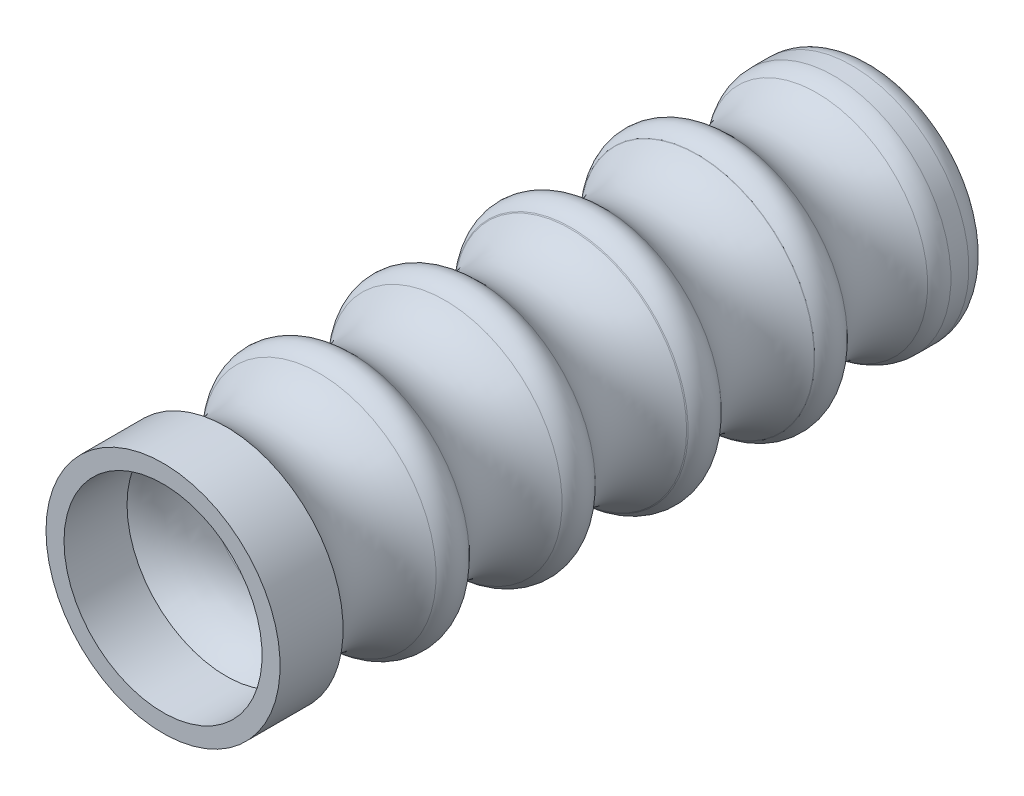
from build123d import *


with BuildPart() as part:
    # Esboço2 → Revolução1 (revolve)
    with BuildSketch(Plane(origin=(0, 0, 0), x_dir=(1, 0, 0), z_dir=(0, 1, 0))):
        with BuildLine():
            Line((8.556122621, -12.161308069), (6.556122621, -12.161308069))
            Line((6.556122621, -12.161308069), (6.556122621, -5.161308069))
            add(Edge.make_bspline(
                [(6.556122621, -5.161308069), (3.760010481, -2.137867698), (4.623751666, 1.838691931)],
                knots=[0, 0, 0, 1, 1, 1], degree=2))
            Line((4.623751666, 1.838691931), (4.623751666, 66.838691931))
            Line((4.623751666, 66.838691931), (6.056124965, 66.838691931))
            ThreePointArc((6.056124965, 66.838691931), (7.823891918, 66.106458884), (8.556124965, 64.338691931))
            Line((8.556124965, 64.338691931), (8.556124965, 62.345597204))
            ThreePointArc((8.556124965, 62.345597204), (8.380648029, 61.334622693), (7.874745323, 60.441916655))
            ThreePointArc((7.874745323, 60.441916655), (6.30241516, 55.504573146), (8.556124965, 50.838699681))
            ThreePointArc((8.556124965, 50.838699681), (9.367195302, 49.017302842), (8.588198185, 47.181959542))
            Line((8.588198185, 47.181959542), (8.556124965, 47.161300319))
            ThreePointArc((8.556124965, 47.161300319), (6.284861149, 42), (8.556124965, 36.838699681))
            ThreePointArc((8.556124965, 36.838699681), (9.367290809, 34.997178824), (8.558781437, 33.154490113))
            Line((8.558781437, 33.154490113), (8.467832014, 33.078995814))
            ThreePointArc((8.467832014, 33.078995814), (6.285121326, 27.939647542), (8.556124965, 22.838699681))
            ThreePointArc((8.556124965, 22.838699681), (9.367290809, 20.997178824), (8.558781437, 19.154490113))
            ThreePointArc((8.558781437, 19.154490113), (6.294951017, 14.000004357), (8.558780391, 8.845518141))
            ThreePointArc((8.558780391, 8.845518141), (9.367289389, 7.002828892), (8.556122621, 5.161308069))
            ThreePointArc((8.556122621, 5.161308069), (6.284853848, 0), (8.556122621, -5.161308069))
            Line((8.556122621, -5.161308069), (8.556122621, -12.161308069))
        make_face()
    revolve(axis=Axis((-4.443877379, 0, -38.836868608), (0, 0, 1)))


solid = part.part
